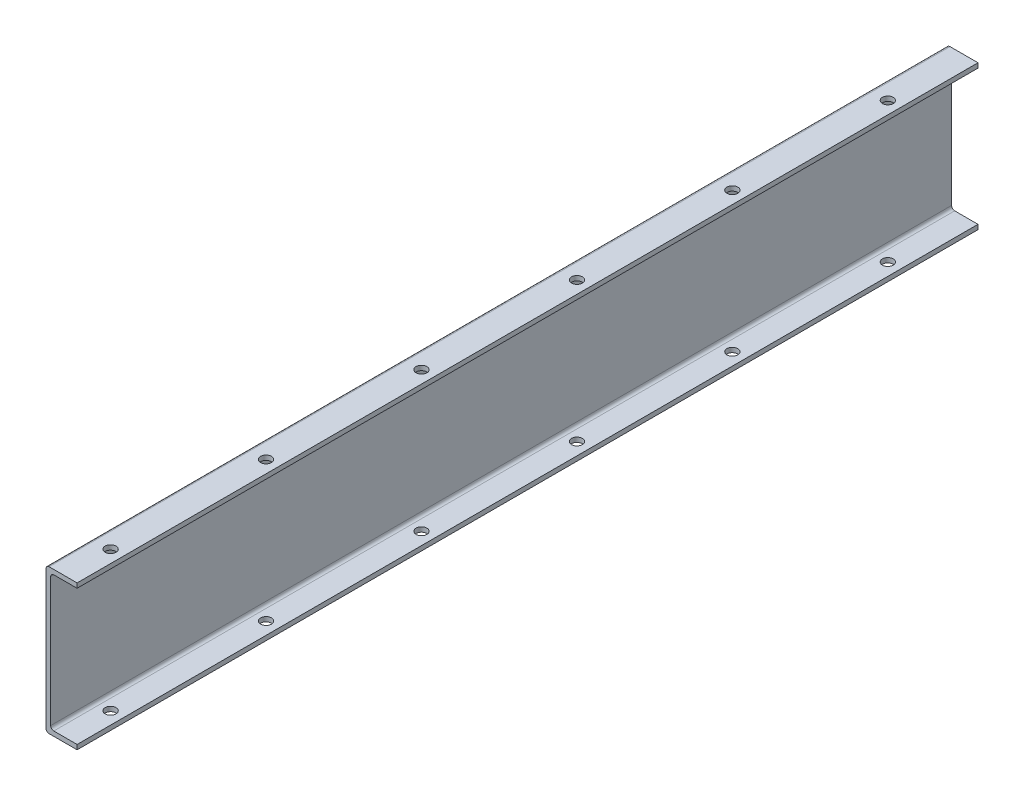
from build123d import *

# Parameters (mm, degrees)
SKETCH1_W           = 1.5
SKETCH1_H           = 43.5
BOSS_EXTRUDE1_DEPTH = 289.77
FILLET1_R           = 1
SKETCH3_R           = 1.75
CUT_EXTRUDE1_DEPTH  = 246.38


with BuildPart() as part:
    # Sketch1 → Boss-Extrude1 (new body)
    with BuildSketch(Plane.XY):
        Rectangle(SKETCH1_W, SKETCH1_H)
        Polygon((-0.75, 23.25), (-0.75, 21.75), (0.75, 21.75), (9.25, 21.75), (9.25, 23.25), align=None)
        Polygon((0.75, -21.75), (-0.75, -21.75), (-0.75, -23.25), (9.25, -23.25), (9.25, -21.75), align=None)
    extrude(amount=BOSS_EXTRUDE1_DEPTH)

    # Fillet1
    fillet1_edges = [part.edges().sort_by_distance(p)[0] for p in [
        (0.75, -21.75, 144.885),
        (-0.75, -23.25, 144.885),
        (-0.75, 23.25, 144.885),
        (0.75, 21.75, 144.885),
    ]]
    fillet(fillet1_edges, radius=FILLET1_R)

    # Sketch3 → Cut-Extrude1 (cut)
    with BuildSketch(Plane(origin=(0, -23.25, 0), x_dir=(-1, 0, 0), z_dir=(0, -1, 0))):
        with Locations((-5.25, -25)):
            Circle(SKETCH3_R)
        with Locations((-5.25, -75)):
            Circle(SKETCH3_R)
        with Locations((-5.25, -125)):
            Circle(SKETCH3_R)
        with Locations((-5.25, -175)):
            Circle(SKETCH3_R)
        with Locations((-5.25, -225)):
            Circle(SKETCH3_R)
        with Locations((-5.25, -275)):
            Circle(SKETCH3_R)
    extrude(amount=-CUT_EXTRUDE1_DEPTH, mode=Mode.SUBTRACT)


solid = part.part
